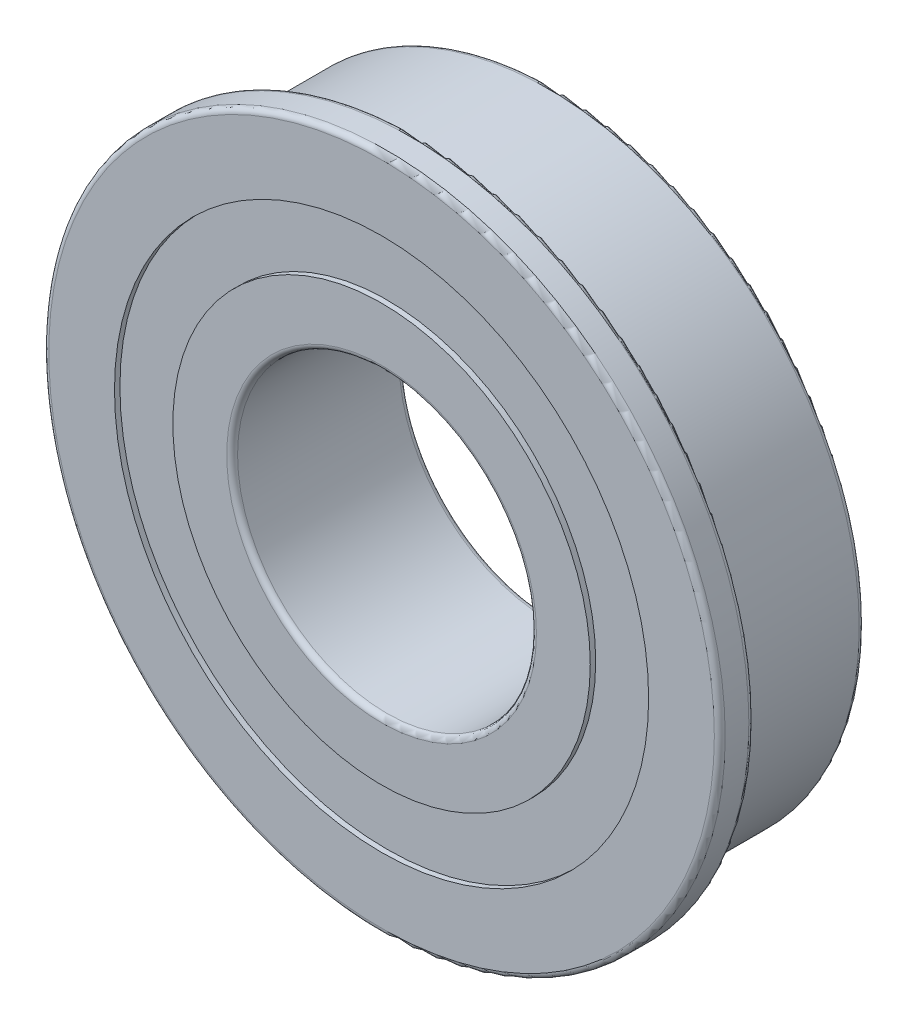
from build123d import *


with BuildPart() as part:
    # Sketch1 → Revolve1 (revolve)
    with BuildSketch(Plane(origin=(0, 0, 0), x_dir=(1, 0, 0), z_dir=(0, 1, 0))):
        with BuildLine():
            Line((14.0375, 3.96875), (12.2875, 3.96875))
            Line((12.2875, 3.96875), (12.2875, 3.71875))
            Line((12.2875, 3.71875), (9.602, 3.71875))
            Line((9.602, 3.71875), (9.602, 3.96875))
            Line((9.602, 3.96875), (7.125, 3.96875))
            ThreePointArc((7.125, 3.96875), (6.948223305, 3.895526695), (6.875, 3.71875))
            Line((6.875, 3.71875), (6.875, -3.71875))
            ThreePointArc((6.875, -3.71875), (6.948223305, -3.895526695), (7.125, -3.96875))
            Line((7.125, -3.96875), (9.602, -3.96875))
            Line((9.602, -3.96875), (9.602, -3.71875))
            Line((9.602, -3.71875), (12.2875, -3.71875))
            Line((12.2875, -3.71875), (12.2875, -3.96875))
            Line((12.2875, -3.96875), (15.31, -3.96875))
            ThreePointArc((15.31, -3.96875), (15.486776695, -3.895526695), (15.56, -3.71875))
            Line((15.56, -3.71875), (15.56, -2.63125))
            ThreePointArc((15.56, -2.63125), (15.486776695, -2.454473305), (15.31, -2.38125))
            Line((15.31, -2.38125), (14.2875, -2.38125))
            ThreePointArc((14.2875, -2.38125), (14.070993649, -2.25625), (14.070993649, -2.00625))
            Line((14.070993649, -2.00625), (14.2875, -1.63125))
            Line((14.2875, -1.63125), (14.2875, 3.71875))
            ThreePointArc((14.2875, 3.71875), (14.214276695, 3.895526695), (14.0375, 3.96875))
        make_face()
    revolve(axis=Axis((0, 0, -3.970003994), (0, 0, 1)))


solid = part.part
